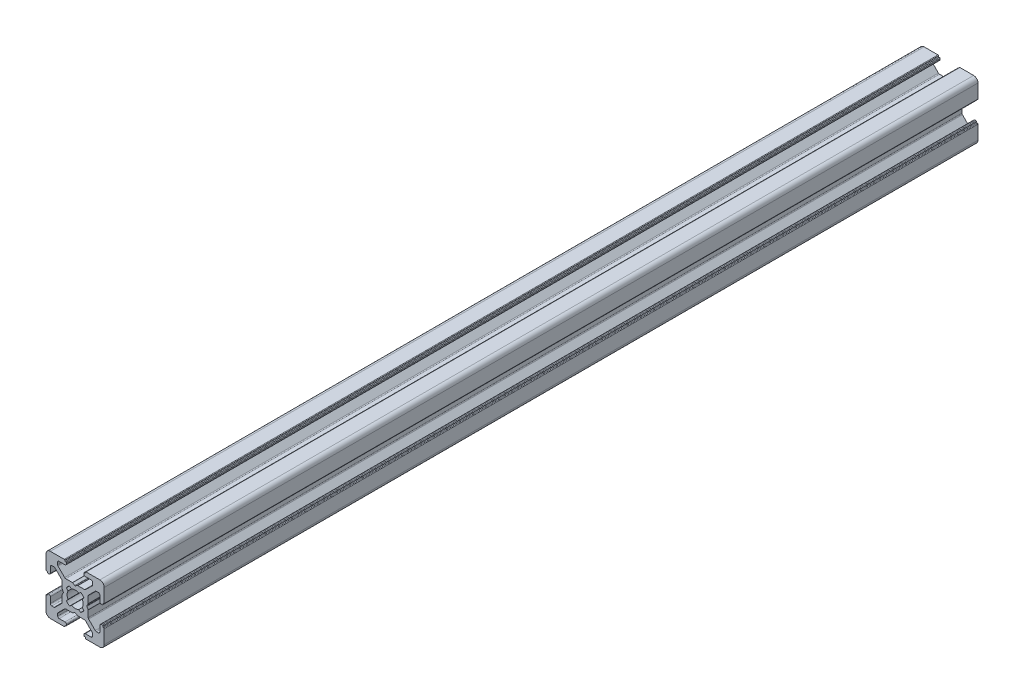
from build123d import *

# Parameters (mm, degrees)
DODANIE_WYCI_GNI_CIE1_DEPTH = 300


with BuildPart() as part:
    # Szkic1 → Dodanie-wyciągnięcie1 (new body)
    with BuildSketch(Plane.XY):
        with BuildLine():
            Line((6.249999773, 6.250000395), (1.5, 6.250000395))
            ThreePointArc((1.5, 6.250000395), (0.439339828, 5.810660567), (0, 4.750000395))
            Line((0, 4.750000395), (0, 0))
            ThreePointArc((0, 0), (0.058578644, -0.141421356), (0.2, -0.2))
            Line((0.2, -0.2), (0.300000268, -0.2))
            ThreePointArc((0.300000268, -0.2), (0.441421624, -0.258578644), (0.500000268, -0.4))
            Line((0.500000268, -0.4), (0.500000268, -0.549999605))
            ThreePointArc((0.500000268, -0.549999605), (0.558578912, -0.691420961), (0.700000268, -0.749999605))
            Line((0.700000268, -0.749999605), (1.000000268, -0.749999605))
            ThreePointArc((1.000000268, -0.749999605), (1.353553659, -0.603552995), (1.500000268, -0.249999605))
            Line((1.500000268, -0.249999605), (1.500000268, 1.75))
            ThreePointArc((1.500000268, 1.75), (1.646446877, 2.103553391), (2.000000268, 2.25))
            Line((2.000000268, 2.25), (2.732233315, 2.25))
            ThreePointArc((2.732233315, 2.25), (2.923575031, 2.211939766), (3.085786706, 2.103553391))
            Line((3.085786706, 2.103553391), (5.353553602, -0.164213506))
            ThreePointArc((5.353553602, -0.164213506), (5.461939977, -0.32642518), (5.500000211, -0.517766896))
            Line((5.500000211, -0.517766896), (5.500000211, -2.796410303))
            ThreePointArc((5.500000211, -2.796410303), (5.506815047, -2.848174114), (5.526795133, -2.896410307))
            Line((5.526795133, -2.896410307), (5.961880159, -3.649999636))
            ThreePointArc((5.961880159, -3.649999636), (5.988675071, -3.749999605), (5.961880159, -3.849999574))
            Line((5.961880159, -3.849999574), (5.526795133, -4.603588902))
            ThreePointArc((5.526795133, -4.603588902), (5.506815046, -4.651825095), (5.500000211, -4.703588906))
            Line((5.500000211, -4.703588906), (5.500000211, -6.982232313))
            ThreePointArc((5.500000211, -6.982232313), (5.461939977, -7.173574029), (5.353553602, -7.335785704))
            Line((5.353553602, -7.335785704), (3.085786706, -9.6035526))
            ThreePointArc((3.085786706, -9.6035526), (2.923575031, -9.711938976), (2.732233315, -9.749999209))
            Line((2.732233315, -9.749999209), (2.000000268, -9.749999209))
            ThreePointArc((2.000000268, -9.749999209), (1.646446877, -9.6035526), (1.500000268, -9.249999209))
            Line((1.500000268, -9.249999209), (1.500000268, -7.249999605))
            ThreePointArc((1.500000268, -7.249999605), (1.353553659, -6.896446214), (1.000000268, -6.749999605))
            Line((1.000000268, -6.749999605), (0.700000268, -6.749999605))
            ThreePointArc((0.700000268, -6.749999605), (0.558578912, -6.808578248), (0.500000268, -6.949999605))
            Line((0.500000268, -6.949999605), (0.500000268, -7.099999209))
            ThreePointArc((0.500000268, -7.099999209), (0.441421624, -7.241420566), (0.300000268, -7.299999209))
            Line((0.300000268, -7.299999209), (0.2, -7.299999209))
            ThreePointArc((0.2, -7.299999209), (0.058578644, -7.358577853), (0, -7.499999209))
            Line((0, -7.499999209), (0, -12.249999605))
            ThreePointArc((0, -12.249999605), (0.439339828, -13.310659776), (1.5, -13.749999605))
            Line((1.5, -13.749999605), (6.249999772, -13.749999605))
            ThreePointArc((6.249999772, -13.749999605), (6.391421129, -13.691420961), (6.449999772, -13.549999605))
            Line((6.449999772, -13.549999605), (6.449999772, -13.449999605))
            ThreePointArc((6.449999772, -13.449999605), (6.508578416, -13.308578248), (6.649999772, -13.249999605))
            Line((6.649999772, -13.249999605), (6.8, -13.249999605))
            ThreePointArc((6.8, -13.249999605), (6.941421356, -13.191420961), (7, -13.049999605))
            Line((7, -13.049999605), (7, -12.749999278))
            ThreePointArc((7, -12.749999278), (6.853553391, -12.396445888), (6.5, -12.249999278))
            Line((6.5, -12.249999278), (4.499999314, -12.249999278))
            ThreePointArc((4.499999314, -12.249999278), (4.146445923, -12.103552669), (3.999999314, -11.749999278))
            Line((3.999999314, -11.749999278), (3.999999314, -11.017766231))
            ThreePointArc((3.999999314, -11.017766231), (4.038059552, -10.826424504), (4.146445941, -10.664212823))
            Line((4.146445941, -10.664212823), (6.414212788, -8.396446197))
            ThreePointArc((6.414212788, -8.396446197), (6.576424456, -8.288059834), (6.767766161, -8.249999605))
            Line((6.767766161, -8.249999605), (9.046409688, -8.249999605))
            ThreePointArc((9.046409688, -8.249999605), (9.098173495, -8.243184771), (9.146409684, -8.223204688))
            Line((9.146409684, -8.223204688), (9.899999955, -7.788119166))
            ThreePointArc((9.899999955, -7.788119166), (10, -7.761324236), (10.100000045, -7.788119166))
            Line((10.100000045, -7.788119166), (10.853590316, -8.223204688))
            ThreePointArc((10.853590316, -8.223204688), (10.901826505, -8.243184771), (10.953590312, -8.249999605))
            Line((10.953590312, -8.249999605), (13.232233839, -8.249999605))
            ThreePointArc((13.232233839, -8.249999605), (13.423575544, -8.288059834), (13.585787212, -8.396446197))
            Line((13.585787212, -8.396446197), (15.853554059, -10.664212823))
            ThreePointArc((15.853554059, -10.664212823), (15.961940448, -10.826424504), (16.000000686, -11.017766231))
            Line((16.000000686, -11.017766231), (16.000000686, -11.749999278))
            ThreePointArc((16.000000686, -11.749999278), (15.853554077, -12.103552669), (15.500000686, -12.249999278))
            Line((15.500000686, -12.249999278), (13.5, -12.249999278))
            ThreePointArc((13.5, -12.249999278), (13.146446609, -12.396445888), (13, -12.749999278))
            Line((13, -12.749999278), (13, -13.049999605))
            ThreePointArc((13, -13.049999605), (13.058578644, -13.191420961), (13.2, -13.249999605))
            Line((13.2, -13.249999605), (13.350000227, -13.249999605))
            ThreePointArc((13.350000227, -13.249999605), (13.491421584, -13.308578248), (13.550000227, -13.449999605))
            Line((13.550000227, -13.449999605), (13.550000227, -13.549999605))
            ThreePointArc((13.550000227, -13.549999605), (13.608578871, -13.691420961), (13.750000227, -13.749999605))
            Line((13.750000227, -13.749999605), (18.5, -13.749999605))
            ThreePointArc((18.5, -13.749999605), (19.560660172, -13.310659776), (20, -12.249999605))
            Line((20, -12.249999605), (20, -7.499999209))
            ThreePointArc((20, -7.499999209), (19.941421356, -7.358577853), (19.8, -7.299999209))
            Line((19.8, -7.299999209), (19.699999732, -7.299999209))
            ThreePointArc((19.699999732, -7.299999209), (19.558578376, -7.241420566), (19.499999732, -7.099999209))
            Line((19.499999732, -7.099999209), (19.499999732, -6.949999605))
            ThreePointArc((19.499999732, -6.949999605), (19.441421088, -6.808578248), (19.299999732, -6.749999605))
            Line((19.299999732, -6.749999605), (18.999999732, -6.749999605))
            ThreePointArc((18.999999732, -6.749999605), (18.646446341, -6.896446214), (18.499999732, -7.249999605))
            Line((18.499999732, -7.249999605), (18.499999732, -9.249999209))
            ThreePointArc((18.499999732, -9.249999209), (18.353553123, -9.6035526), (17.999999732, -9.749999209))
            Line((17.999999732, -9.749999209), (17.267766685, -9.749999209))
            ThreePointArc((17.267766685, -9.749999209), (17.076424969, -9.711938976), (16.914213294, -9.6035526))
            Line((16.914213294, -9.6035526), (14.646446398, -7.335785704))
            ThreePointArc((14.646446398, -7.335785704), (14.538060023, -7.173574029), (14.499999789, -6.982232313))
            Line((14.499999789, -6.982232313), (14.499999789, -4.703588906))
            ThreePointArc((14.499999789, -4.703588906), (14.493184953, -4.651825095), (14.473204867, -4.603588902))
            Line((14.473204867, -4.603588902), (14.038119841, -3.849999574))
            ThreePointArc((14.038119841, -3.849999574), (14.011324929, -3.749999605), (14.038119841, -3.649999636))
            Line((14.038119841, -3.649999636), (14.473204867, -2.896410307))
            ThreePointArc((14.473204867, -2.896410307), (14.493184953, -2.848174114), (14.499999789, -2.796410303))
            Line((14.499999789, -2.796410303), (14.499999789, -0.517766896))
            ThreePointArc((14.499999789, -0.517766896), (14.538060023, -0.32642518), (14.646446398, -0.164213506))
            Line((14.646446398, -0.164213506), (16.914213294, 2.103553391))
            ThreePointArc((16.914213294, 2.103553391), (17.076424969, 2.211939766), (17.267766685, 2.25))
            Line((17.267766685, 2.25), (17.999999732, 2.25))
            ThreePointArc((17.999999732, 2.25), (18.353553123, 2.103553391), (18.499999732, 1.75))
            Line((18.499999732, 1.75), (18.499999732, -0.249999605))
            ThreePointArc((18.499999732, -0.249999605), (18.646446341, -0.603552995), (18.999999732, -0.749999605))
            Line((18.999999732, -0.749999605), (19.299999732, -0.749999605))
            ThreePointArc((19.299999732, -0.749999605), (19.441421088, -0.691420961), (19.499999732, -0.549999605))
            Line((19.499999732, -0.549999605), (19.499999732, -0.4))
            ThreePointArc((19.499999732, -0.4), (19.558578376, -0.258578644), (19.699999732, -0.2))
            Line((19.699999732, -0.2), (19.8, -0.2))
            ThreePointArc((19.8, -0.2), (19.941421356, -0.141421356), (20, 0))
            Line((20, 0), (20, 4.750000395))
            ThreePointArc((20, 4.750000395), (19.560660172, 5.810660567), (18.5, 6.250000395))
            Line((18.5, 6.250000395), (13.750000228, 6.250000395))
            ThreePointArc((13.750000228, 6.250000395), (13.608578871, 6.191421752), (13.550000228, 6.050000395))
            Line((13.550000228, 6.050000395), (13.550000228, 5.950000395))
            ThreePointArc((13.550000228, 5.950000395), (13.491421584, 5.808579039), (13.350000228, 5.750000395))
            Line((13.350000228, 5.750000395), (13.2, 5.750000395))
            ThreePointArc((13.2, 5.750000395), (13.058578644, 5.691421752), (13, 5.550000395))
            Line((13, 5.550000395), (13, 5.250000069))
            ThreePointArc((13, 5.250000069), (13.146446609, 4.896446678), (13.5, 4.750000069))
            Line((13.5, 4.750000069), (15.500000686, 4.750000069))
            ThreePointArc((15.500000686, 4.750000069), (15.853554077, 4.603553459), (16.000000686, 4.250000069))
            Line((16.000000686, 4.250000069), (16.000000686, 3.517767022))
            ThreePointArc((16.000000686, 3.517767022), (15.961940448, 3.326425294), (15.853554059, 3.164213614))
            Line((15.853554059, 3.164213614), (13.585787212, 0.896446988))
            ThreePointArc((13.585787212, 0.896446988), (13.423575544, 0.788060624), (13.232233839, 0.750000395))
            Line((13.232233839, 0.750000395), (10.953590312, 0.750000395))
            ThreePointArc((10.953590312, 0.750000395), (10.901826505, 0.743185561), (10.853590316, 0.723205479))
            Line((10.853590316, 0.723205479), (10.100000045, 0.288119957))
            ThreePointArc((10.100000045, 0.288119957), (10, 0.261325027), (9.899999955, 0.288119957))
            Line((9.899999955, 0.288119957), (9.146409684, 0.723205479))
            ThreePointArc((9.146409684, 0.723205479), (9.098173495, 0.743185561), (9.046409688, 0.750000395))
            Line((9.046409688, 0.750000395), (6.767766161, 0.750000395))
            ThreePointArc((6.767766161, 0.750000395), (6.576424456, 0.788060624), (6.414212788, 0.896446988))
            Line((6.414212788, 0.896446988), (4.146445941, 3.164213614))
            ThreePointArc((4.146445941, 3.164213614), (4.038059552, 3.326425294), (3.999999314, 3.517767022))
            Line((3.999999314, 3.517767022), (3.999999314, 4.250000069))
            ThreePointArc((3.999999314, 4.250000069), (4.146445923, 4.603553459), (4.499999314, 4.750000069))
            Line((4.499999314, 4.750000069), (6.5, 4.750000069))
            ThreePointArc((6.5, 4.750000069), (6.853553391, 4.896446678), (7, 5.250000069))
            Line((7, 5.250000069), (7, 5.550000395))
            ThreePointArc((7, 5.550000395), (6.941421356, 5.691421752), (6.8, 5.750000395))
            Line((6.8, 5.750000395), (6.649999772, 5.750000395))
            ThreePointArc((6.649999772, 5.750000395), (6.508578416, 5.808579039), (6.449999772, 5.950000395))
            Line((6.449999772, 5.950000395), (6.449999772, 6.050000395))
            ThreePointArc((6.449999772, 6.050000395), (6.391421129, 6.191421752), (6.249999773, 6.250000395))
        make_face()
        with BuildLine():
            Line((7.007825047, -1.840068643), (7.554704576, -2.491814288))
            ThreePointArc((7.554704576, -2.491814288), (7.25, -3.749999605), (7.554704576, -5.008184922))
            Line((7.554704576, -5.008184922), (7.007825046, -5.659930566))
            ThreePointArc((7.007825046, -5.659930566), (7.488262739, -6.25841009), (8.08610498, -6.739640567))
            Line((8.08610498, -6.739640567), (8.741814564, -6.195294967))
            ThreePointArc((8.741814564, -6.195294967), (10, -6.499999605), (11.258185436, -6.195294967))
            Line((11.258185436, -6.195294967), (11.913895019, -6.739640567))
            ThreePointArc((11.913895019, -6.739640567), (12.511737261, -6.25841009), (12.992174953, -5.659930566))
            Line((12.992174953, -5.659930566), (12.445295423, -5.008184922))
            ThreePointArc((12.445295423, -5.008184922), (12.75, -3.749999605), (12.445295423, -2.491814288))
            Line((12.445295423, -2.491814288), (12.992174953, -1.840068643))
            ThreePointArc((12.992174953, -1.840068643), (12.511737261, -1.241589119), (11.913895019, -0.760358642))
            Line((11.913895019, -0.760358642), (11.258185436, -1.304704243))
            ThreePointArc((11.258185436, -1.304704243), (10, -0.999999605), (8.741814564, -1.304704243))
            Line((8.741814564, -1.304704243), (8.08610498, -0.760358642))
            ThreePointArc((8.08610498, -0.760358642), (7.488262739, -1.241589119), (7.007825047, -1.840068643))
        make_face(mode=Mode.SUBTRACT)
    extrude(amount=DODANIE_WYCI_GNI_CIE1_DEPTH)


solid = part.part
